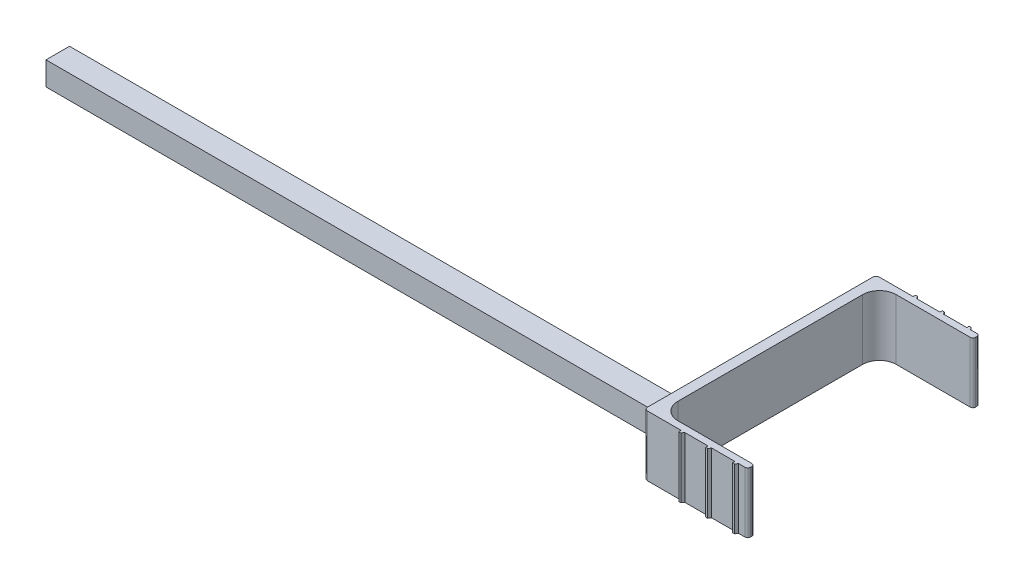
from build123d import *

# Parameters (mm, degrees)
BOSS_EXTRUDE1_DEPTH = 18
FILLET1_R           = 5
FILLET2_R           = 1
SKETCH1_3_W         = 190
SKETCH1_3_H         = 7
BOSS_EXTRUDE2_DEPTH = 7
FILLET3_R           = 10


with BuildPart() as part:
    # Sketch1 → Boss-Extrude1 (new body)
    with BuildSketch(Plane(origin=(0, 0, 0), x_dir=(1, 0, 0), z_dir=(0, 1, 0))):
        with BuildLine():
            Line((7.053352185, -22.5), (7.053352185, -34.5))
            Line((7.053352185, -34.5), (18.053352185, -34.5))
            Line((18.053352185, -34.5), (18.053352185, -35.2))
            Line((18.053352185, -35.2), (18.651371079, -35.2))
            Line((18.651371079, -35.2), (19.151371079, -34.5))
            Line((19.151371079, -34.5), (26.053352185, -34.5))
            Line((26.053352185, -34.5), (26.053352185, -35.2))
            Line((26.053352185, -35.2), (26.651371079, -35.2))
            Line((26.651371079, -35.2), (27.151371079, -34.5))
            Line((27.151371079, -34.5), (34.053352185, -34.5))
            Line((34.053352185, -34.5), (34.053352185, -35.2))
            Line((34.053352185, -35.2), (34.651371079, -35.2))
            Line((34.651371079, -35.2), (35.151371079, -34.5))
            Line((35.151371079, -34.5), (37.053352185, -34.5))
            ThreePointArc((37.053352185, -34.5), (37.61903761, -34.265685425), (37.853352185, -33.7))
            Line((37.853352185, -33.7), (37.853352185, -33.3))
            ThreePointArc((37.853352185, -33.3), (37.61903761, -32.734314575), (37.053352185, -32.5))
            Line((37.053352185, -32.5), (10.053352185, -32.5))
            Line((10.053352185, -32.5), (10.053352185, 0))
            Line((10.053352185, 0), (7.053352185, 0))
            Line((7.053352185, 0), (7.053352185, -15.5))
            Line((7.053352185, -15.5), (7.053352185, -22.5))
        make_face()
    extrude(amount=BOSS_EXTRUDE1_DEPTH)

    # Fillet1
    fillet1_edges = [part.edges().sort_by_distance(p)[0] for p in [
        (10.053352185, 9, 32.5),
    ]]
    fillet(fillet1_edges, radius=FILLET1_R)

    # Fillet2
    fillet2_edges = [part.edges().sort_by_distance(p)[0] for p in [
        (7.053352185, 9, 34.5),
    ]]
    fillet(fillet2_edges, radius=FILLET2_R)

    # Mirror1: part across plane


with BuildPart() as part_1:
    add(part.part)
    add(part.part.mirror(Plane(origin=(0, 18, 0), x_dir=(1, 0, 0), z_dir=(0, 0, -1))))

    # Sketch1_3 → Boss-Extrude2 (add)
    with BuildSketch(Plane(origin=(0, 0, 0), x_dir=(1, 0, 0), z_dir=(0, 1, 0))):
        with Locations((-87.946647815, -19)):
            Rectangle(SKETCH1_3_W, SKETCH1_3_H)
    extrude(amount=BOSS_EXTRUDE2_DEPTH)

    # Fillet3
    fillet3_edges = [part_1.edges().sort_by_distance(p)[0] for p in [
        (7.053352185, 3.5, 22.5),
        (7.053352185, 3.5, 15.5),
        (7.053352185, 7, 19),
    ]]
    fillet(fillet3_edges, radius=FILLET3_R)


solid = part_1.part
